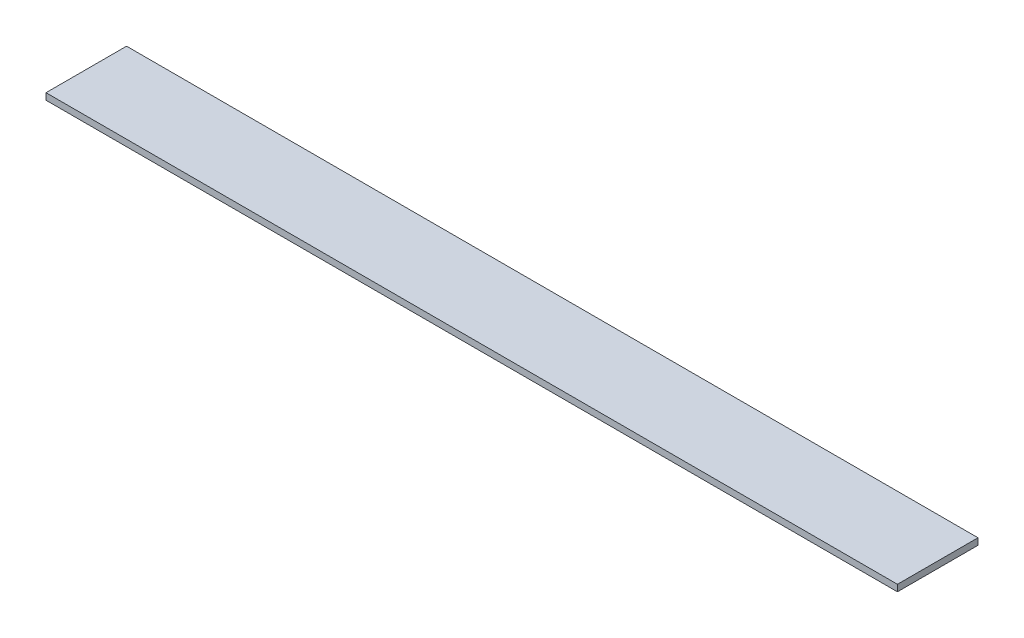
from build123d import *

# Parameters (mm, degrees)
SKETCH1_W           = 130
SKETCH1_H           = 12.3
BOSS_EXTRUDE1_DEPTH = 1


with BuildPart() as part:
    # Sketch1 → Boss-Extrude1 (new body)
    with BuildSketch(Plane(origin=(0, 0, 0), x_dir=(1, 0, 0), z_dir=(0, 1, 0))):
        with Locations((65, 6.15)):
            Rectangle(SKETCH1_W, SKETCH1_H)
    extrude(amount=BOSS_EXTRUDE1_DEPTH)


solid = part.part
